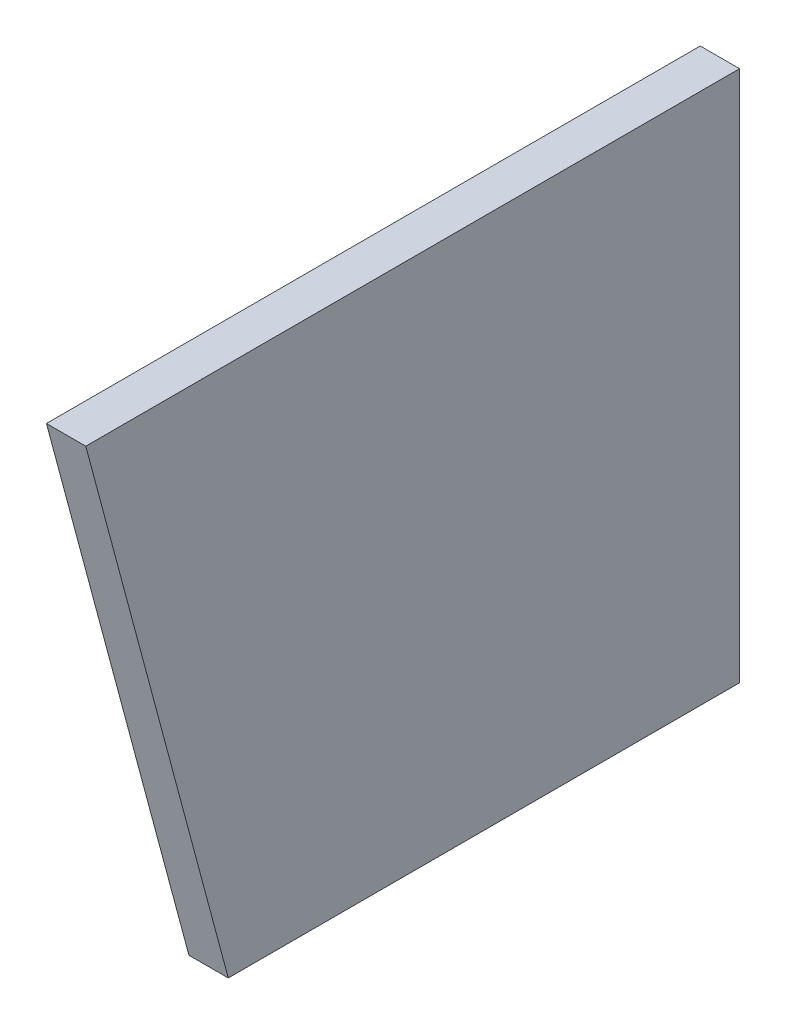
from build123d import *

# Parameters (mm, degrees)
SKETCH2_W           = 12.7
SKETCH2_H           = 171.7294
BOSS_EXTRUDE2_DEPTH = 381
CUT_EXTRUDE1_DEPTH  = 13.7


with BuildPart() as part:
    # Sketch2 → Boss-Extrude2 (new body)
    with BuildSketch(Plane.XY):
        with Locations((-6.35, 85.8647)):
            Rectangle(SKETCH2_W, SKETCH2_H)
    extrude(amount=BOSS_EXTRUDE2_DEPTH)

    # Sketch3 → Cut-Extrude1 (cut, through all)
    with BuildSketch(Plane(origin=(0, 0, 0), x_dir=(0, 0, -1), z_dir=(1, 0, 0))):
        Polygon((-165.1, 0), (-211.114754047, 171.7294), (-381, 171.7294), (-381, 0), align=None)
    extrude(amount=-CUT_EXTRUDE1_DEPTH, mode=Mode.SUBTRACT)


solid = part.part
